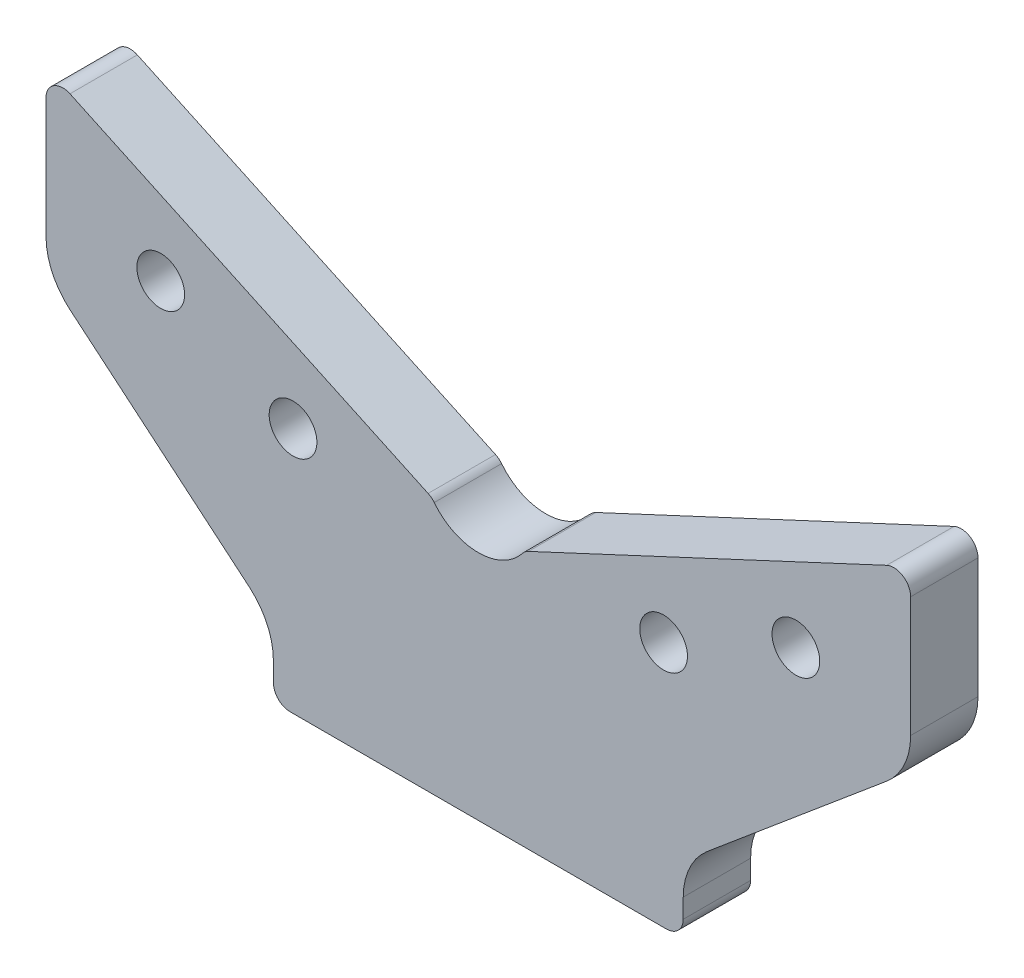
from build123d import *

# Parameters (mm, degrees)
EXTRUDE1_DEPTH         = 12
M10_GEVINDHULLER_D     = 8.5
M10_GEVINDHULLER_DEPTH = 22
M10_GEVINDHULLER_TIP   = 2.553657631


with BuildPart() as part:
    # Sketch1 → Extrude1 (new body)
    with BuildSketch(Plane.XY):
        with BuildLine():
            Line((36.5, 6.420773039), (36.5, 3))
            ThreePointArc((36.5, 3), (35.621320344, 0.878679656), (33.5, 0))
            Line((33.5, 0), (0, 0))
            Line((0, 0), (-33.5, 0))
            ThreePointArc((-33.5, 0), (-35.621320344, 0.878679656), (-36.5, 3))
            Line((-36.5, 3), (-36.5, 6.420773039))
            ThreePointArc((-36.5, 6.420773039), (-37.624306556, 11.49219218), (-40.786548684, 15.613306357))
            Line((-40.786548684, 15.613306357), (-72.713451316, 42.40315858))
            ThreePointArc((-72.713451316, 42.40315858), (-75.875693444, 46.524272757), (-77, 51.595691898))
            Line((-77, 51.595691898), (-77, 73))
            ThreePointArc((-77, 73), (-75.611898825, 75.530174337), (-72.732145215, 75.718923361))
            Line((-72.732145215, 75.718923361), (-8.939617358, 45.971979088))
            ThreePointArc((-8.939617358, 45.971979088), (-8.345295598, 45.605139594), (-7.851901649, 45.110819879))
            ThreePointArc((-7.851901649, 45.110819879), (0, 41.303367053), (7.851901649, 45.110819879))
            ThreePointArc((7.851901649, 45.110819879), (8.345295598, 45.605139594), (8.939617358, 45.971979088))
            Line((8.939617358, 45.971979088), (72.732145215, 75.718923361))
            ThreePointArc((72.732145215, 75.718923361), (75.611898825, 75.530174337), (77, 73))
            Line((77, 73), (77, 51.595691898))
            ThreePointArc((77, 51.595691898), (75.875693444, 46.524272757), (72.713451316, 42.40315858))
            Line((72.713451316, 42.40315858), (40.786548684, 15.613306357))
            ThreePointArc((40.786548684, 15.613306357), (37.624306556, 11.49219218), (36.5, 6.420773039))
        make_face()
    extrude(amount=EXTRUDE1_DEPTH)

    # M10 gevindhuller
    with Locations(Plane.XY.offset(12)):
        with Locations((-33, 43.950984745), (-56.564002463, 54.93905955), (56.564002463, 54.93905955), (33, 43.950984745)):
            Hole(M10_GEVINDHULLER_D / 2, depth=M10_GEVINDHULLER_DEPTH)
            with Locations((0, 0, -(M10_GEVINDHULLER_DEPTH + M10_GEVINDHULLER_TIP / 2))):  # 118° drill point
                Cone(0, M10_GEVINDHULLER_D / 2, M10_GEVINDHULLER_TIP, mode=Mode.SUBTRACT)


solid = part.part
